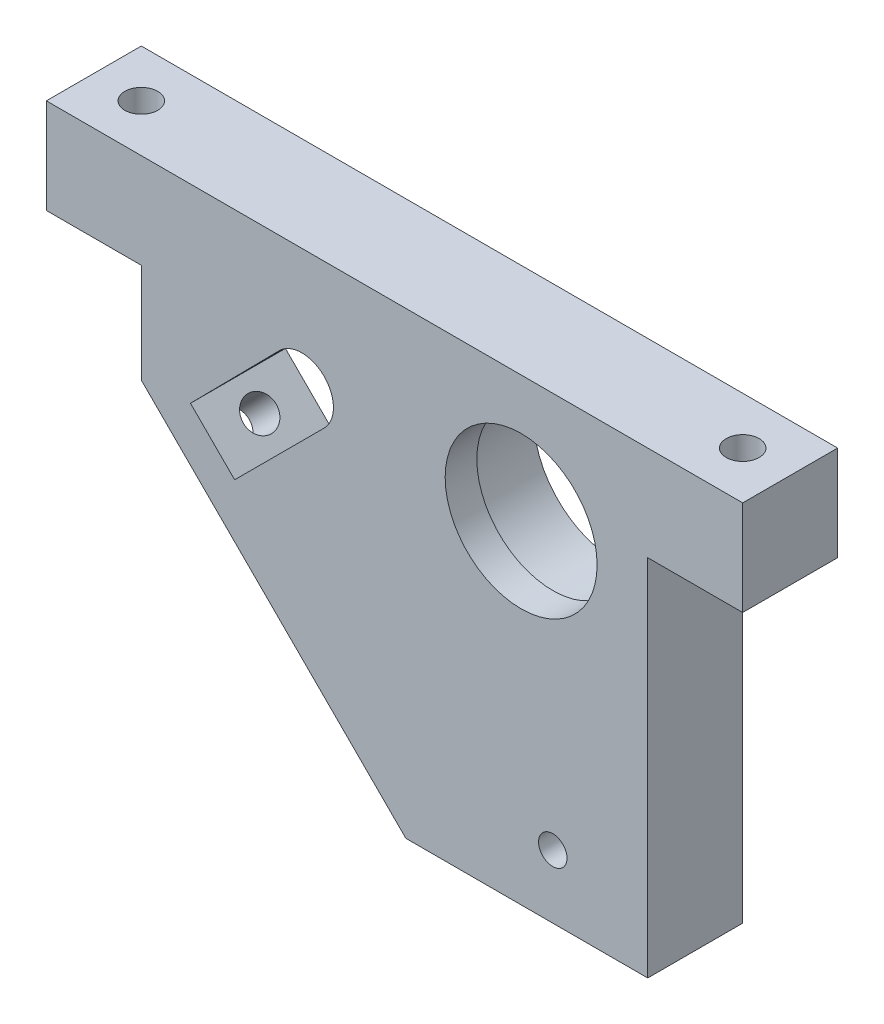
from build123d import *

# Parameters (mm, degrees)
SKETCH_1_R          = 12
SKETCH_1_R_2        = 2.25
EXTRUDE_1_DEPTH     = 15
SKETCH_2_R          = 13
CUT_EXTRUDE_1_DEPTH = 10
SKETCH_3_R          = 2.6
CUT_EXTRUDE_2_DEPTH = 73.5
SKETCH_5_R          = 2.6
CUT_EXTRUDE_3_DEPTH = 10


with BuildPart() as part:
    # 草图1 → 凸台-拉伸1 (new body)
    with BuildSketch(Plane.XY):
        Polygon((-33.800989673, 26.429197467), (-27.44059998, 26.429197467), (-18.800989673, 26.429197467), (-18.800989673, 10.718519348), (22.988332208, -31.070802533), (61.199010327, -31.070802533), (61.199010327, 26.429197467), (76.199010327, 26.429197467), (76.199010327, 41.429197467), (56.199010327, 41.429197467), (-33.800989673, 41.429197467), align=None)
        with Locations((41.199010327, 21.429197467)):
            Circle(SKETCH_1_R, mode=Mode.SUBTRACT)
        with Locations((46.199010327, -21.070802533)):
            Circle(SKETCH_1_R_2, mode=Mode.SUBTRACT)
        with BuildLine():
            Line((-11.034973369, 11.437784418), (2.9923212, 25.648765615))
            ThreePointArc((2.9923212, 25.648765615), (10.086164278, 25.671985824), (10.063536665, 18.57814083))
            Line((10.063536665, 18.57814083), (-4.055896558, 4.458707607))
            Line((-4.055896558, 4.458707607), (-11.034973369, 11.437784418))
        make_face(mode=Mode.SUBTRACT)
    extrude(amount=EXTRUDE_1_DEPTH)

    # 草图2 → 切除-拉伸1 (cut)
    with BuildSketch(Plane(origin=(0, 0, 0), x_dir=(-1, 0, 0), z_dir=(0, 0, -1))):
        with Locations((-41.199010327, 21.429197467)):
            Circle(SKETCH_2_R)
    extrude(amount=-CUT_EXTRUDE_1_DEPTH, mode=Mode.SUBTRACT)

    # 草图3 → 切除-拉伸2 (cut, through all)
    with BuildSketch(Plane(origin=(0, 41.429197467, 0), x_dir=(1, 0, 0), z_dir=(0, 1, 0))):
        with Locations((-26.300989673, -7.5)):
            Circle(SKETCH_3_R)
        with Locations((68.699010327, -7.5)):
            Circle(SKETCH_3_R)
    extrude(amount=-CUT_EXTRUDE_2_DEPTH, mode=Mode.SUBTRACT)

    # 草图5 → 切除-拉伸3 (cut)
    with BuildSketch(Plane(origin=(-4.041235162, -4.041235162, 0), x_dir=(0, 0, 1), z_dir=(-0.707106781, -0.707106781, 0))):
        with Locations((7.5, 11.023445006)):
            Circle(SKETCH_5_R)
    extrude(amount=-CUT_EXTRUDE_3_DEPTH, mode=Mode.SUBTRACT)


solid = part.part
